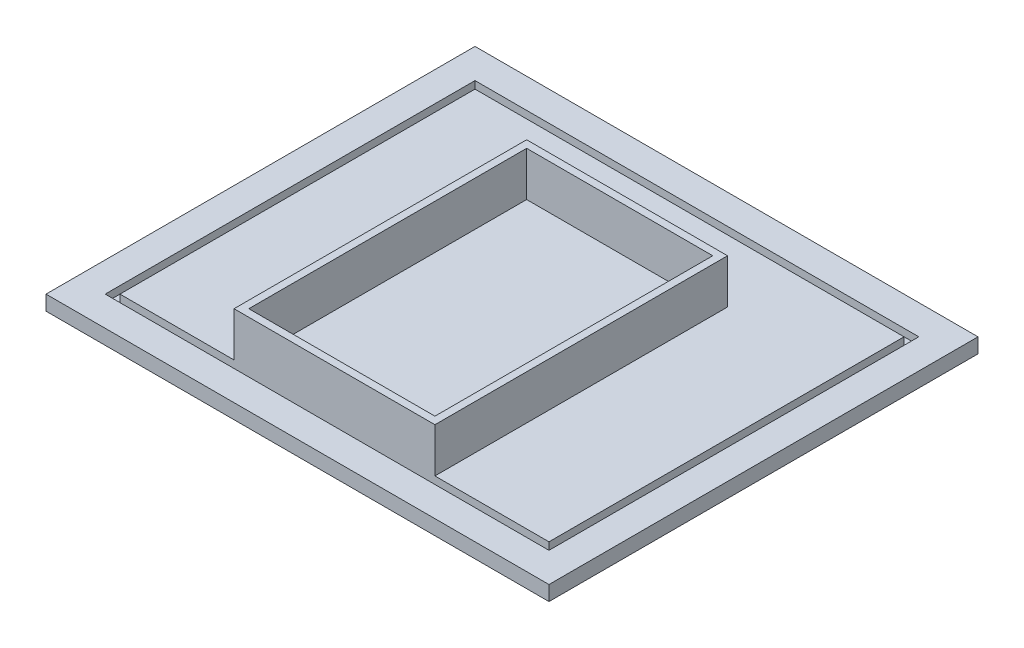
from build123d import *

# Parameters (mm, degrees)
SKETCH1_W           = 170
SKETCH1_H           = 145
BOSS_EXTRUDE1_DEPTH = 5
SKETCH2_W           = 150
SKETCH2_H           = 125
SKETCH2_W_2         = 145
SKETCH2_H_2         = 120
CUT_EXTRUDE1_DEPTH  = 2.5
SKETCH4_W           = 67.9
SKETCH4_H           = 98.9
SKETCH4_W_2         = 62.9
SKETCH4_H_2         = 93.9
BOSS_EXTRUDE2_DEPTH = 15


with BuildPart() as part:
    # Sketch1 → Boss-Extrude1 (new body)
    with BuildSketch(Plane(origin=(0, 0, 0), x_dir=(1, 0, 0), z_dir=(0, 1, 0))):
        Rectangle(SKETCH1_W, SKETCH1_H)
    extrude(amount=BOSS_EXTRUDE1_DEPTH)

    # Sketch2 → Cut-Extrude1 (cut)
    with BuildSketch(Plane(origin=(0, 5, 0), x_dir=(1, 0, 0), z_dir=(0, 1, 0))):
        Rectangle(SKETCH2_W, SKETCH2_H)
        Rectangle(SKETCH2_W_2, SKETCH2_H_2, mode=Mode.SUBTRACT)
    extrude(amount=-CUT_EXTRUDE1_DEPTH, mode=Mode.SUBTRACT)

    # Sketch4 → Boss-Extrude2 (add)
    with BuildSketch(Plane(origin=(0, 5, 0), x_dir=(1, 0, 0), z_dir=(0, 1, 0))):
        with Locations((0, -10.55)):
            Rectangle(SKETCH4_W, SKETCH4_H)
        with Locations((0, -10.55)):
            Rectangle(SKETCH4_W_2, SKETCH4_H_2, mode=Mode.SUBTRACT)
    extrude(amount=BOSS_EXTRUDE2_DEPTH)


solid = part.part
